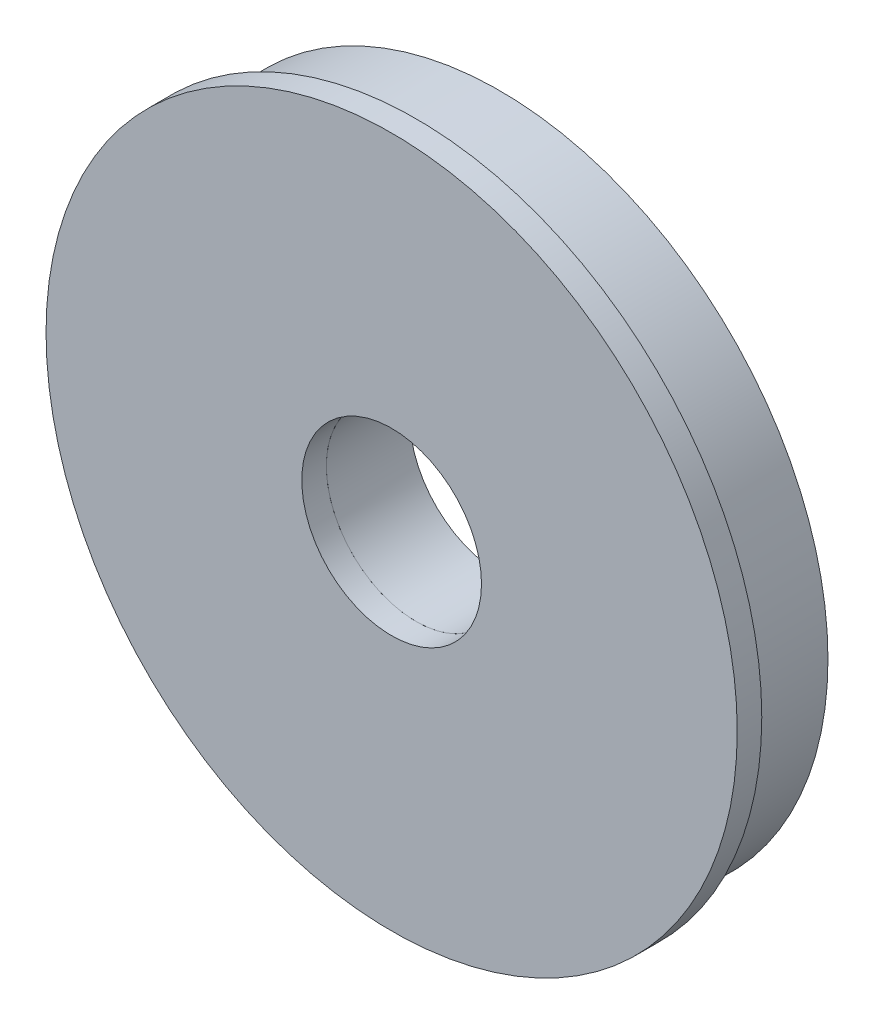
from build123d import *

# Parameters (mm, degrees)
SKETCH1_R      = 12.7
SKETCH1_R_2    = 3.302
EXTRUDE1_DEPTH = 0.9017
SKETCH2_R      = 12.065
SKETCH2_R_2    = 3.302
EXTRUDE2_DEPTH = 3.06705


with BuildPart() as part:
    # Sketch1 → Extrude1 (new body)
    with BuildSketch(Plane.XY):
        Circle(SKETCH1_R)
        Circle(SKETCH1_R_2, mode=Mode.SUBTRACT)
    extrude(amount=-EXTRUDE1_DEPTH)


with BuildPart() as body_2:
    # Sketch2 → Extrude2 (new body)
    with BuildSketch(Plane(origin=(0, 0, -0.9017), x_dir=(-1, 0, 0), z_dir=(0, 0, -1))):
        Circle(SKETCH2_R)
        Circle(SKETCH2_R_2, mode=Mode.SUBTRACT)
    extrude(amount=EXTRUDE2_DEPTH)


solid = Compound([part.part, body_2.part])
